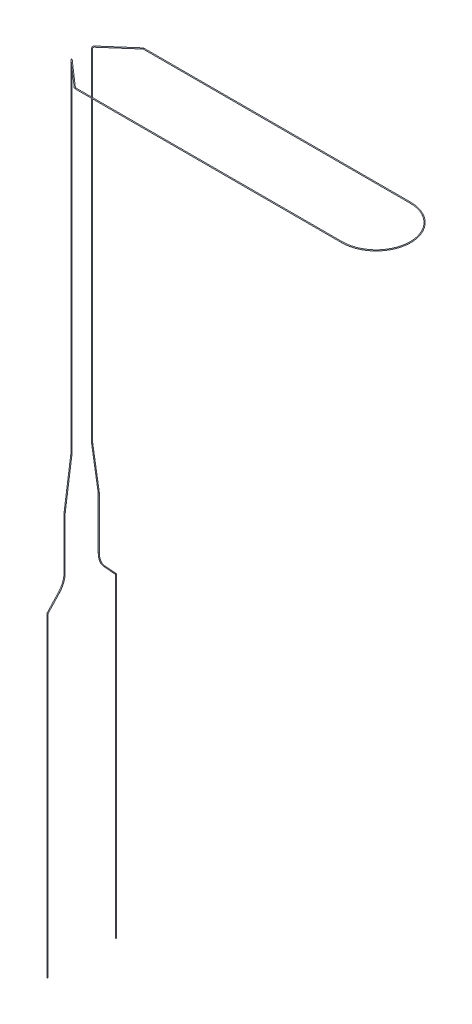
from build123d import *

# Parameters (mm, degrees)
BALAYAGE1_PROFILE_R = 0.25


with BuildPart() as part:
    # Balayage1: sweep along a curve in space
    with BuildLine() as balayage1_path:
        Line((0, -16.22597154, 20), (0, -200, 20))
        ThreePointArc((0, -15.547683614, 19.734796223), (0, -15.861826118, 19.931342102), (0, -16.22597154, 20))
        Line((0, -8.449455116, 13.182445327), (0, -15.547683614, 19.734796223))
        ThreePointArc((0, -0.31, 10), (0, -4.679745068, 10.823894773), (0, -8.449455116, 13.182445327))
        Line((0, 0, 10), (0, -0.31, 10))
        Line((0, 0, 10), (0, 29.289321881, 10))
        ThreePointArc((0, 29.289321881, 10), (0, 29.998212082, 9.974842088), (0, 30.703535444, 9.899494937))
        Line((0, 30.703535444, 9.899494937), (0, 57.296464556, 6.100505063))
        ThreePointArc((0, 58.710678119, 6), (0, 58.001787918, 6.025157912), (0, 57.296464556, 6.100505063))
        Line((0, 257, 6), (0, 58.710678119, 6))
        ThreePointArc((0.752576695, 258, 6.658504608), (0.220424611, 257.707106781, 6.192871534), (0, 257, 6))
        Line((0.752576695, 258, 6.658504608), (15.717230508, 258, 19.752576695))
        ThreePointArc((16.375735116, 258, 20), (16.024008443, 258, 19.936102744), (15.717230508, 258, 19.752576695))
        Line((16.375735116, 258, 20), (172, 258, 20))
        ThreePointArc((172, 258, 20), (192, 258, 0), (172, 258, -20))
        Line((16.375735116, 258, -20), (172, 258, -20))
        ThreePointArc((15.717230508, 258, -19.752576695), (16.024008443, 258, -19.936102744), (16.375735116, 258, -20))
        Line((0.752576695, 258, -6.658504608), (15.717230508, 258, -19.752576695))
        ThreePointArc((0, 257, -6), (0.220424611, 257.707106781, -6.192871534), (0.752576695, 258, -6.658504608))
        Line((0, 257, -6), (0, 58.710678119, -6))
        ThreePointArc((0, 57.296464556, -6.100505063), (0, 58.001787918, -6.025157912), (0, 58.710678119, -6))
        Line((0, 30.703535444, -9.899494937), (0, 57.296464556, -6.100505063))
        ThreePointArc((0, 30.703535444, -9.899494937), (0, 29.998212082, -9.974842088), (0, 29.289321881, -10))
        Line((0, 0, -10), (0, 29.289321881, -10))
        Line((0, 0, -10), (0, -0.31, -10))
        ThreePointArc((0, -8.449455116, -13.182445327), (0, -4.679745068, -10.823894773), (0, -0.31, -10))
        Line((0, -8.449455116, -13.182445327), (0, -15.547683614, -19.734796223))
        ThreePointArc((0, -16.22597154, -20), (0, -15.861826118, -19.931342102), (0, -15.547683614, -19.734796223))
        Line((0, -16.22597154, -20), (0, -200, -20))
    # Balayage1 profile (on start of the path) → Balayage1 (sweep)
    with BuildSketch(Plane(origin=(0, -200, -20), x_dir=(1, 0, 0), z_dir=(0, 1, 0))):
        Circle(BALAYAGE1_PROFILE_R)
    sweep(path=balayage1_path.line)


solid = part.part
